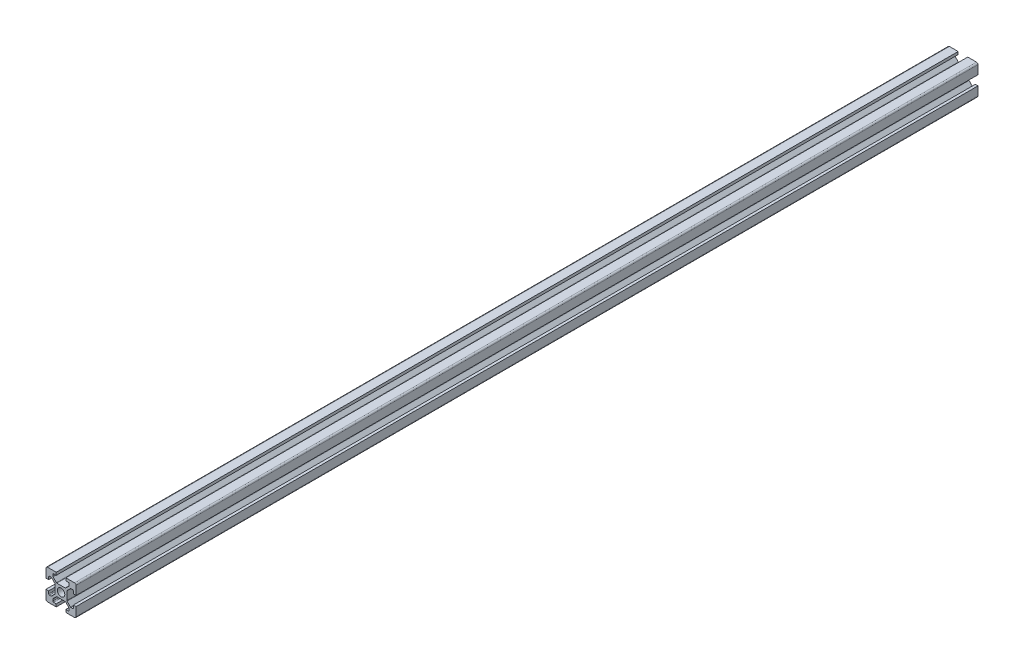
from build123d import *

# Parameters (mm, degrees)
SKETCH1_R           = 2.5
BOSS_EXTRUDE1_DEPTH = 300
FILLET1_R           = 1
FILLET2_R           = 0.5
FILLET3_R           = 0.5
FILLET4_R           = 0.5
FILLET5_R           = 0.5
BOSS_EXTRUDE2_DEPTH = 300


with BuildPart() as part:
    # Sketch1 → Boss-Extrude1 (new body)
    with BuildSketch(Plane.XY):
        Polygon((13.2, 0), (13.2, 1.8), (15.45, 1.8), (15.45, 3.6), (12.95, 6.1), (7.05, 6.1), (4.55, 3.6), (4.55, 1.8), (6.8, 1.8), (6.8, 0), (0, 0), (0, 6.8), (1.8, 6.8), (1.8, 4.55), (3.6, 4.55), (6.1, 7.05), (6.1, 12.95), (3.6, 15.45), (1.8, 15.45), (1.8, 13.2), (0, 13.2), (0, 20), (6.8, 20), (6.8, 18.2), (4.55, 18.2), (4.55, 16.4), (7.05, 13.9), (12.95, 13.9), (15.45, 16.4), (15.45, 18.2), (13.2, 18.2), (13.2, 20), (20, 20), (20, 13.2), (18.2, 13.2), (18.2, 15.45), (16.4, 15.45), (13.9, 12.95), (13.9, 7.05), (16.4, 4.55), (18.2, 4.55), (18.2, 6.8), (20, 6.8), (20, 0), align=None)
        with Locations((10, 10)):
            Circle(SKETCH1_R, mode=Mode.SUBTRACT)
    extrude(amount=BOSS_EXTRUDE1_DEPTH)

    # Fillet1
    fillet1_edges = [part.edges().sort_by_distance(p)[0] for p in [
        (0, 0, 150),
        (0, 20, 150),
        (20, 20, 150),
        (20, 0, 150),
    ]]
    fillet(fillet1_edges, radius=FILLET1_R)

    # Fillet2
    fillet2_edges = [part.edges().sort_by_distance(p)[0] for p in [
        (4.55, 18.2, 150),
        (4.55, 16.4, 150),
        (7.05, 13.9, 150),
        (12.95, 13.9, 150),
        (15.45, 16.4, 150),
        (15.45, 18.2, 150),
    ]]
    fillet(fillet2_edges, radius=FILLET2_R)

    # Fillet3
    fillet3_edges = [part.edges().sort_by_distance(p)[0] for p in [
        (18.2, 15.45, 150),
        (16.4, 15.45, 150),
        (13.9, 12.95, 150),
        (13.9, 7.05, 150),
        (16.4, 4.55, 150),
        (18.2, 4.55, 150),
    ]]
    fillet(fillet3_edges, radius=FILLET3_R)

    # Fillet4
    fillet4_edges = [part.edges().sort_by_distance(p)[0] for p in [
        (1.8, 4.55, 150),
        (3.6, 4.55, 150),
        (6.1, 7.05, 150),
        (6.1, 12.95, 150),
        (3.6, 15.45, 150),
        (1.8, 15.45, 150),
    ]]
    fillet(fillet4_edges, radius=FILLET4_R)

    # Fillet5
    fillet5_edges = [part.edges().sort_by_distance(p)[0] for p in [
        (15.45, 1.8, 150),
        (15.45, 3.6, 150),
        (12.95, 6.1, 150),
        (7.05, 6.1, 150),
        (4.55, 3.6, 150),
        (4.55, 1.8, 150),
    ]]
    fillet(fillet5_edges, radius=FILLET5_R)

    # Sketch4 → Boss-Extrude2 (add)
    with BuildSketch(Plane(origin=(0, 0, 0), x_dir=(-1, 0, 0), z_dir=(0, 0, -1))):
        with BuildLine():
            Line((-13.2, 20), (-19, 20))
            ThreePointArc((-19, 20), (-19.707106781, 19.707106781), (-20, 19))
            Line((-20, 19), (-20, 13.2))
            Line((-20, 13.2), (-18.2, 13.2))
            Line((-18.2, 13.2), (-18.2, 14.95))
            ThreePointArc((-18.2, 14.95), (-18.053553391, 15.303553391), (-17.7, 15.45))
            Line((-17.7, 15.45), (-16.607106781, 15.45))
            ThreePointArc((-16.607106781, 15.45), (-16.415765065, 15.411939766), (-16.253553391, 15.303553391))
            Line((-16.253553391, 15.303553391), (-14.046446609, 13.096446609))
            ThreePointArc((-14.046446609, 13.096446609), (-13.938060234, 12.934234935), (-13.9, 12.742893219))
            Line((-13.9, 12.742893219), (-13.9, 7.257106781))
            ThreePointArc((-13.9, 7.257106781), (-13.938060234, 7.065765065), (-14.046446609, 6.903553391))
            Line((-14.046446609, 6.903553391), (-16.253553391, 4.696446609))
            ThreePointArc((-16.253553391, 4.696446609), (-16.415765065, 4.588060234), (-16.607106781, 4.55))
            Line((-16.607106781, 4.55), (-17.7, 4.55))
            ThreePointArc((-17.7, 4.55), (-18.053553391, 4.696446609), (-18.2, 5.05))
            Line((-18.2, 5.05), (-18.2, 6.8))
            Line((-18.2, 6.8), (-20, 6.8))
            Line((-20, 6.8), (-20, 1))
            ThreePointArc((-20, 1), (-19.707106781, 0.292893219), (-19, 0))
            Line((-19, 0), (-13.2, 0))
            Line((-13.2, 0), (-13.2, 1.8))
            Line((-13.2, 1.8), (-14.95, 1.8))
            ThreePointArc((-14.95, 1.8), (-15.303553391, 1.946446609), (-15.45, 2.3))
            Line((-15.45, 2.3), (-15.45, 3.392893219))
            ThreePointArc((-15.45, 3.392893219), (-15.411939766, 3.584234935), (-15.303553391, 3.746446609))
            Line((-15.303553391, 3.746446609), (-13.096446609, 5.953553391))
            ThreePointArc((-13.096446609, 5.953553391), (-12.934234935, 6.061939766), (-12.742893219, 6.1))
            Line((-12.742893219, 6.1), (-7.257106781, 6.1))
            ThreePointArc((-7.257106781, 6.1), (-7.065765065, 6.061939766), (-6.903553391, 5.953553391))
            Line((-6.903553391, 5.953553391), (-4.696446609, 3.746446609))
            ThreePointArc((-4.696446609, 3.746446609), (-4.588060234, 3.584234935), (-4.55, 3.392893219))
            Line((-4.55, 3.392893219), (-4.55, 2.3))
            ThreePointArc((-4.55, 2.3), (-4.696446609, 1.946446609), (-5.05, 1.8))
            Line((-5.05, 1.8), (-6.8, 1.8))
            Line((-6.8, 1.8), (-6.8, 0))
            Line((-6.8, 0), (-1, 0))
            ThreePointArc((-1, 0), (-0.292893219, 0.292893219), (0, 1))
            Line((0, 1), (0, 6.8))
            Line((0, 6.8), (-1.8, 6.8))
            Line((-1.8, 6.8), (-1.8, 5.05))
            ThreePointArc((-1.8, 5.05), (-1.946446609, 4.696446609), (-2.3, 4.55))
            Line((-2.3, 4.55), (-3.392893219, 4.55))
            ThreePointArc((-3.392893219, 4.55), (-3.584234935, 4.588060234), (-3.746446609, 4.696446609))
            Line((-3.746446609, 4.696446609), (-5.953553391, 6.903553391))
            ThreePointArc((-5.953553391, 6.903553391), (-6.061939766, 7.065765065), (-6.1, 7.257106781))
            Line((-6.1, 7.257106781), (-6.1, 12.742893219))
            ThreePointArc((-6.1, 12.742893219), (-6.061939766, 12.934234935), (-5.953553391, 13.096446609))
            Line((-5.953553391, 13.096446609), (-3.746446609, 15.303553391))
            ThreePointArc((-3.746446609, 15.303553391), (-3.584234935, 15.411939766), (-3.392893219, 15.45))
            Line((-3.392893219, 15.45), (-2.3, 15.45))
            ThreePointArc((-2.3, 15.45), (-1.946446609, 15.303553391), (-1.8, 14.95))
            Line((-1.8, 14.95), (-1.8, 13.2))
            Line((-1.8, 13.2), (0, 13.2))
            Line((0, 13.2), (0, 19))
            ThreePointArc((0, 19), (-0.292893219, 19.707106781), (-1, 20))
            Line((-1, 20), (-6.8, 20))
            Line((-6.8, 20), (-6.8, 18.2))
            Line((-6.8, 18.2), (-5.05, 18.2))
            ThreePointArc((-5.05, 18.2), (-4.696446609, 18.053553391), (-4.55, 17.7))
            Line((-4.55, 17.7), (-4.55, 16.607106781))
            ThreePointArc((-4.55, 16.607106781), (-4.588060234, 16.415765065), (-4.696446609, 16.253553391))
            Line((-4.696446609, 16.253553391), (-6.903553391, 14.046446609))
            ThreePointArc((-6.903553391, 14.046446609), (-7.065765065, 13.938060234), (-7.257106781, 13.9))
            Line((-7.257106781, 13.9), (-12.742893219, 13.9))
            ThreePointArc((-12.742893219, 13.9), (-12.934234935, 13.938060234), (-13.096446609, 14.046446609))
            Line((-13.096446609, 14.046446609), (-15.303553391, 16.253553391))
            ThreePointArc((-15.303553391, 16.253553391), (-15.411939766, 16.415765065), (-15.45, 16.607106781))
            Line((-15.45, 16.607106781), (-15.45, 17.7))
            ThreePointArc((-15.45, 17.7), (-15.303553391, 18.053553391), (-14.95, 18.2))
            Line((-14.95, 18.2), (-13.2, 18.2))
            Line((-13.2, 18.2), (-13.2, 20))
        make_face()
    extrude(amount=BOSS_EXTRUDE2_DEPTH)


solid = part.part
